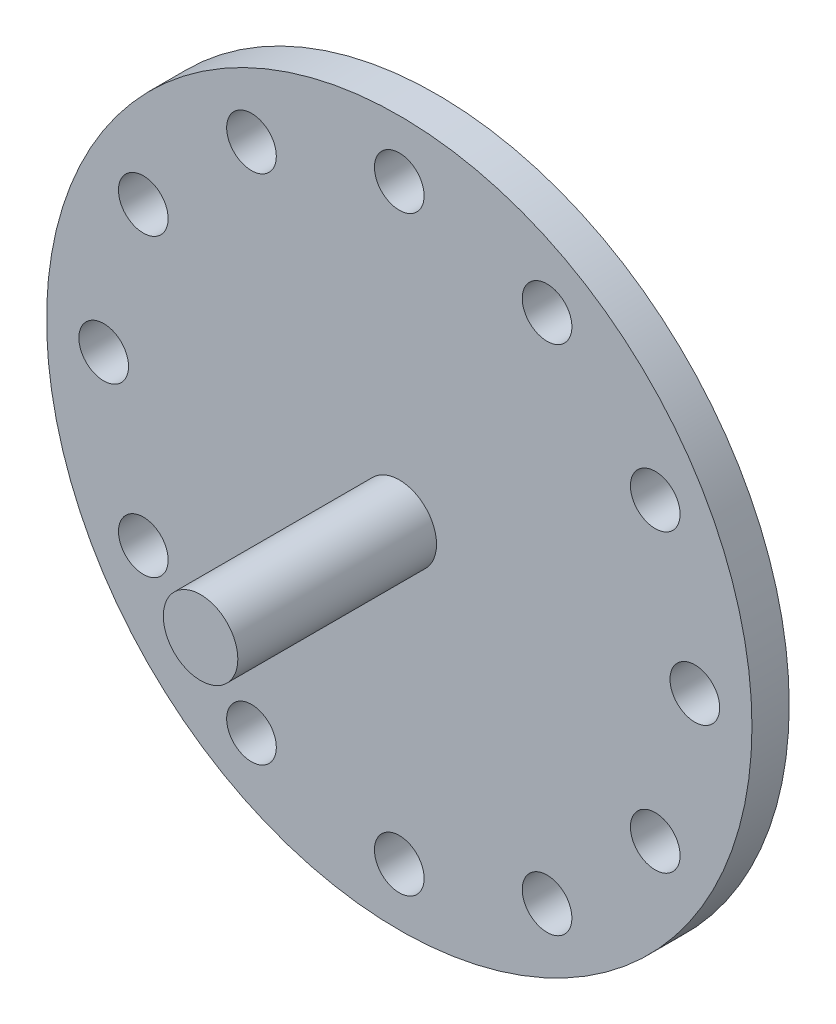
from build123d import *

# Parameters (mm, degrees)
SKETCH1_R           = 28.4
SKETCH1_R_2         = 2
BOSS_EXTRUDE1_DEPTH = 3
SKETCH2_R           = 3
BOSS_EXTRUDE2_DEPTH = 16


with BuildPart() as part:
    # Sketch1 → Boss-Extrude1 (new body)
    with BuildSketch(Plane.XY):
        Circle(SKETCH1_R)
        with Locations((23.8, 0)):
            Circle(SKETCH1_R_2, mode=Mode.SUBTRACT)
        with Locations((20.61140461, -11.9)):
            Circle(SKETCH1_R_2, mode=Mode.SUBTRACT)
        with Locations((11.9, -20.61140461)):
            Circle(SKETCH1_R_2, mode=Mode.SUBTRACT)
        with Locations((0, -23.8)):
            Circle(SKETCH1_R_2, mode=Mode.SUBTRACT)
        with Locations((-11.9, -20.61140461)):
            Circle(SKETCH1_R_2, mode=Mode.SUBTRACT)
        with Locations((-20.61140461, -11.9)):
            Circle(SKETCH1_R_2, mode=Mode.SUBTRACT)
        with Locations((-23.8, 0)):
            Circle(SKETCH1_R_2, mode=Mode.SUBTRACT)
        with Locations((-20.61140461, 11.9)):
            Circle(SKETCH1_R_2, mode=Mode.SUBTRACT)
        with Locations((-11.9, 20.61140461)):
            Circle(SKETCH1_R_2, mode=Mode.SUBTRACT)
        with Locations((0, 23.8)):
            Circle(SKETCH1_R_2, mode=Mode.SUBTRACT)
        with Locations((11.9, 20.61140461)):
            Circle(SKETCH1_R_2, mode=Mode.SUBTRACT)
        with Locations((20.61140461, 11.9)):
            Circle(SKETCH1_R_2, mode=Mode.SUBTRACT)
    extrude(amount=BOSS_EXTRUDE1_DEPTH)

    # Sketch2 → Boss-Extrude2 (add)
    with BuildSketch(Plane.XY.offset(3)):
        Circle(SKETCH2_R)
    extrude(amount=BOSS_EXTRUDE2_DEPTH)


solid = part.part
